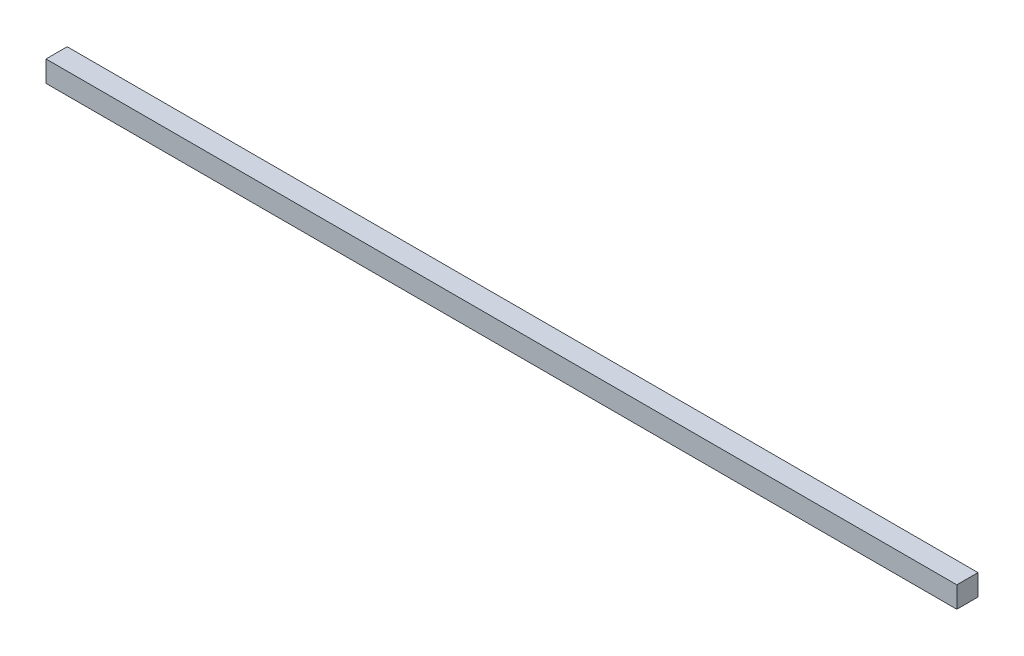
from build123d import *

# Parameters (mm, degrees)
SKETCH1_W           = 430
SKETCH1_H           = 10
BOSS_EXTRUDE1_DEPTH = 10


with BuildPart() as part:
    # Sketch1 → Boss-Extrude1 (new body)
    with BuildSketch(Plane(origin=(0, 0, 0), x_dir=(1, 0, 0), z_dir=(0, 1, 0))):
        Rectangle(SKETCH1_W, SKETCH1_H)
    extrude(amount=BOSS_EXTRUDE1_DEPTH)


solid = part.part
